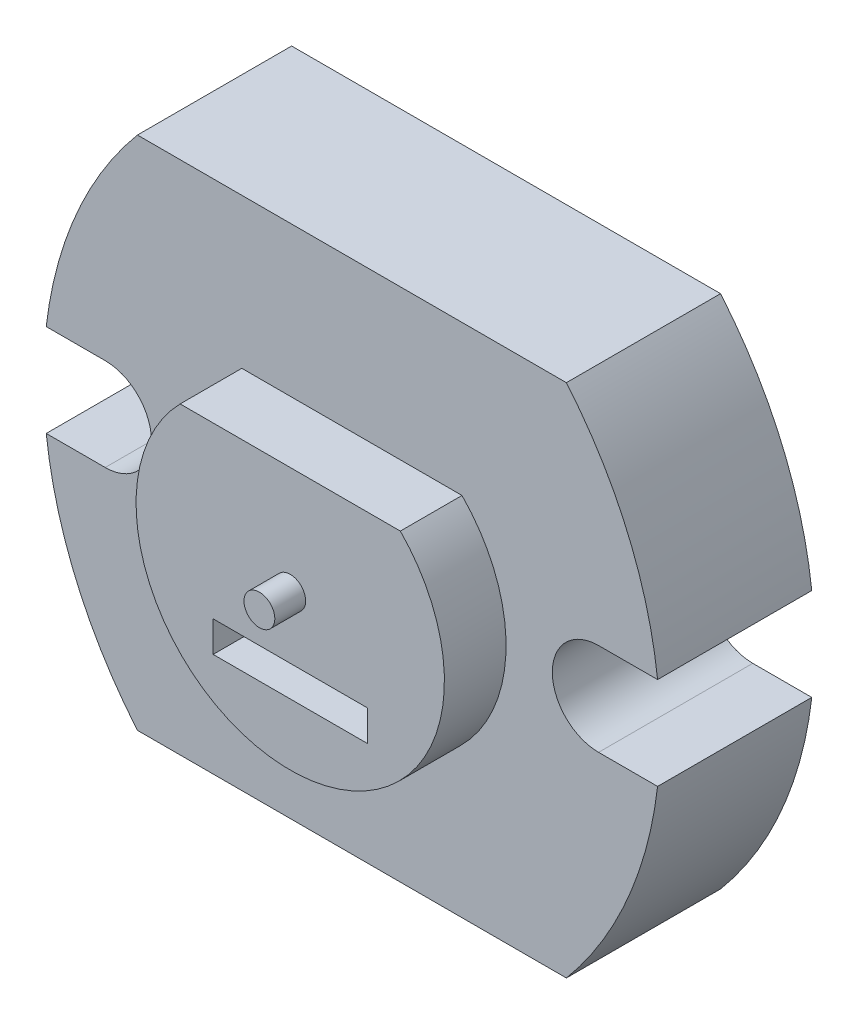
from build123d import *

# Parameters (mm, degrees)
BOSS_EXTRUDE2_DEPTH = 5
CUT_EXTRUDE1_DEPTH  = 5
SKETCH3_R           = 0.5
BOSS_EXTRUDE3_DEPTH = 3
BOSS_EXTRUDE4_DEPTH = 2
SKETCH5_W           = 5
SKETCH5_H           = 1
CUT_EXTRUDE2_DEPTH  = 2


with BuildPart() as part:
    # Sketch1 → Boss-Extrude2 (new body)
    with BuildSketch(Plane.XY):
        with BuildLine():
            ThreePointArc((-6.955420634, 8.36), (-9.215164105, 4.44856897), (-10, 0))
            Line((-10, 0), (10, 0))
            ThreePointArc((10, 0), (9.215164105, 4.44856897), (6.955420634, 8.36))
            Line((6.955420634, 8.36), (-6.955420634, 8.36))
        make_face()
        with BuildLine():
            Line((10, 0), (-10, 0))
            ThreePointArc((-10, 0), (-9.215164105, -4.44856897), (-6.955420634, -8.36))
            Line((-6.955420634, -8.36), (6.955420634, -8.36))
            ThreePointArc((6.955420634, -8.36), (9.215164105, -4.44856897), (10, 0))
        make_face()
    extrude(amount=BOSS_EXTRUDE2_DEPTH)

    # Sketch2 → Cut-Extrude1 (cut)
    with BuildSketch(Plane.XY.offset(5)):
        with BuildLine():
            Line((-8, 1.5), (-9.91317157, 1.5))
            Line((-9.91317157, 1.5), (-10.317130361, 1.5))
            ThreePointArc((-10.317130361, 1.5), (-10.425602087, 0), (-10.317130361, -1.5))
            Line((-10.317130361, -1.5), (-9.91317157, -1.5))
            Line((-9.91317157, -1.5), (-8, -1.5))
            ThreePointArc((-8, -1.5), (-6.5, 0), (-8, 1.5))
        make_face()
        with BuildLine():
            Line((8, -1.5), (9.91317157, -1.5))
            Line((9.91317157, -1.5), (10.317130361, -1.5))
            ThreePointArc((10.317130361, -1.5), (10.425602087, 0), (10.317130361, 1.5))
            Line((10.317130361, 1.5), (9.91317157, 1.5))
            Line((9.91317157, 1.5), (8, 1.5))
            ThreePointArc((8, 1.5), (6.5, 0), (8, -1.5))
        make_face()
    extrude(amount=-CUT_EXTRUDE1_DEPTH, mode=Mode.SUBTRACT)

    # Sketch3 → Boss-Extrude3 (add)
    with BuildSketch(Plane.XY.offset(5)):
        Circle(SKETCH3_R)
    extrude(amount=BOSS_EXTRUDE3_DEPTH)

    # Sketch4 → Boss-Extrude4 (add)
    with BuildSketch(Plane.XY.offset(5)):
        with BuildLine():
            Line((-3.570714214, 3.5), (3.570714214, 3.5))
            ThreePointArc((3.570714214, 3.5), (0, -5), (-3.570714214, 3.5))
        make_face()
    extrude(amount=BOSS_EXTRUDE4_DEPTH)

    # Sketch5 → Cut-Extrude2 (cut)
    with BuildSketch(Plane.XY.offset(7)):
        with Locations((0, -2.5)):
            Rectangle(SKETCH5_W, SKETCH5_H)
    extrude(amount=-CUT_EXTRUDE2_DEPTH, mode=Mode.SUBTRACT)


solid = part.part
